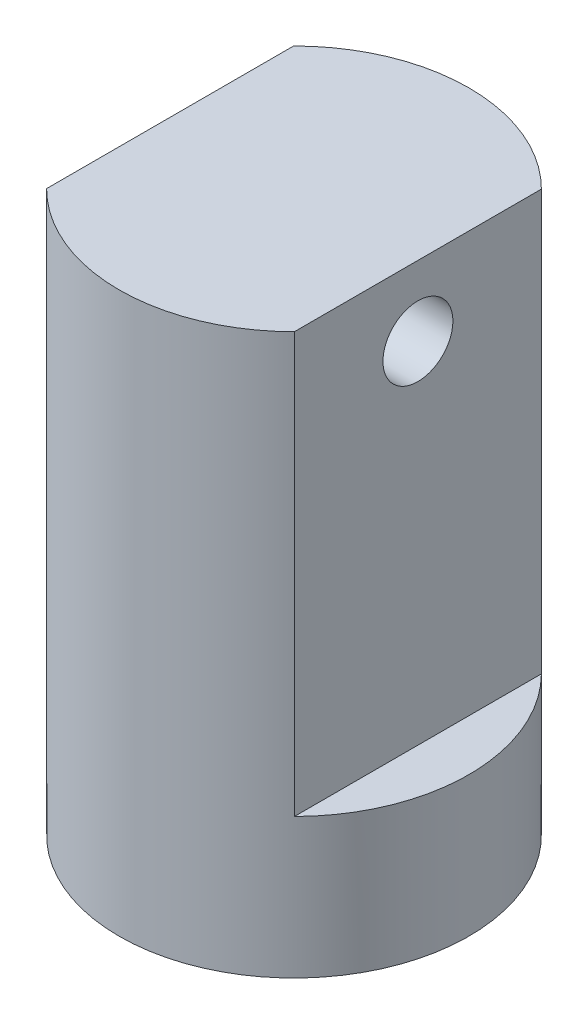
from build123d import *

# Parameters (mm, degrees)
SKETCH1_R           = 25
BOSS_EXTRUDE1_DEPTH = 80
CUT_EXTRUDE1_DEPTH  = 60
SKETCH3_R           = 5
CUT_EXTRUDE2_DEPTH  = 60
SKETCH4_R           = 5
CUT_EXTRUDE3_DEPTH  = 30


with BuildPart() as part:
    # Sketch1 → Boss-Extrude1 (new body)
    with BuildSketch(Plane(origin=(0, 0, 0), x_dir=(1, 0, 0), z_dir=(0, 1, 0))):
        Circle(SKETCH1_R)
    extrude(amount=BOSS_EXTRUDE1_DEPTH)

    # Sketch2 → Cut-Extrude1 (cut)
    with BuildSketch(Plane(origin=(0, 80, 0), x_dir=(1, 0, 0), z_dir=(0, 1, 0))):
        with BuildLine():
            Line((-17.708192822, -17.647093443), (-17.708192822, 17.647093443))
            ThreePointArc((-17.708192822, 17.647093443), (-25, 0), (-17.708192822, -17.647093443))
        make_face()
        with BuildLine():
            ThreePointArc((25, 0), (23.10524638, 9.547124684), (17.708192822, 17.647093443))
            Line((17.708192822, 17.647093443), (17.708192822, -17.647093443))
            ThreePointArc((17.708192822, -17.647093443), (23.10524638, -9.547124684), (25, 0))
        make_face()
    extrude(amount=-CUT_EXTRUDE1_DEPTH, mode=Mode.SUBTRACT)

    # Sketch3 → Cut-Extrude2 (cut)
    with BuildSketch(Plane(origin=(17.708192822, 0, 0), x_dir=(0, 0, -1), z_dir=(1, 0, 0))):
        with Locations((0, 70)):
            Circle(SKETCH3_R)
    extrude(amount=-CUT_EXTRUDE2_DEPTH, mode=Mode.SUBTRACT)

    # Sketch4 → Cut-Extrude3 (cut)
    with BuildSketch(Plane.XZ):
        Circle(SKETCH4_R)
    extrude(amount=-CUT_EXTRUDE3_DEPTH, mode=Mode.SUBTRACT)


solid = part.part
